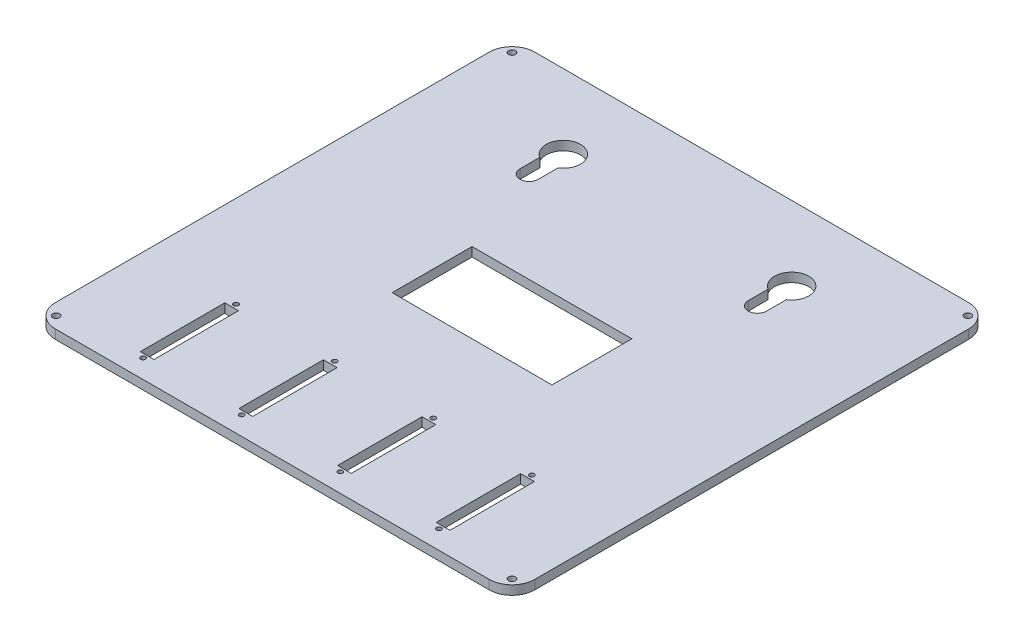
from build123d import *

# Parameters (mm, degrees)
SKETCH1_W              = 210
SKETCH1_H              = 210
MAINEXTRUDE_DEPTH      = 2
SKETCH1_6_R            = 1.5
SCREWHOLES_DEPTH       = 2
ROUNDEDCORNERS_R       = 10
SKETCH2_R              = 1.05
SKETCH2_W              = 6
SKETCH2_H              = 37
SKETCH2_W_2            = 70
SKETCH2_H_2            = 35
KNOTCHES_SLIDERS_DEPTH = 4
SKETCH6_R              = 2
SKETCH6_R_2            = 0.98
PCBHOLES_DEPTH         = 4
PCBROUNDS_R            = 2


with BuildPart() as part:
    # Sketch1 → MainExtrude (new body, symmetric)
    with BuildSketch(Plane(origin=(0, 0, 0), x_dir=(1, 0, 0), z_dir=(0, 1, 0))):
        Rectangle(SKETCH1_W, SKETCH1_H)
    extrude(amount=MAINEXTRUDE_DEPTH, both=True)

    # Sketch1_6 → ScrewHoles (cut, symmetric)
    with BuildSketch(Plane(origin=(0, 0, 0), x_dir=(1, 0, 0), z_dir=(0, 1, 0))):
        with Locations((-99.833273811, 99.833273811)):
            Circle(SKETCH1_6_R)
        with Locations((-99.833273811, -99.833273811)):
            Circle(SKETCH1_6_R)
        with Locations((99.833273811, -99.833273811)):
            Circle(SKETCH1_6_R)
        with Locations((99.833273811, 99.833273811)):
            Circle(SKETCH1_6_R)
    extrude(amount=SCREWHOLES_DEPTH, both=True, mode=Mode.SUBTRACT)

    # RoundedCorners
    roundedcorners_edges = [part.edges().sort_by_distance(p)[0] for p in [
        (-105, 0, -105),
        (-105, 0, 105),
        (105, 0, 105),
        (105, 0, -105),
    ]]
    fillet(roundedcorners_edges, radius=ROUNDEDCORNERS_R)

    # Sketch2 → Knotches_Sliders (cut)
    with BuildSketch(Plane(origin=(0, 2, 0), x_dir=(1, 0, 0), z_dir=(0, 1, 0))):
        with Locations((-64.8, -96.8)):
            Circle(SKETCH2_R)
        with Locations((-64.8, -56.1)):
            Circle(SKETCH2_R)
        with Locations((-21.6, -56.1)):
            Circle(SKETCH2_R)
        with Locations((-21.6, -96.8)):
            Circle(SKETCH2_R)
        with Locations((21.6, -56.1)):
            Circle(SKETCH2_R)
        with Locations((21.6, -96.8)):
            Circle(SKETCH2_R)
        with Locations((64.8, -56.1)):
            Circle(SKETCH2_R)
        with Locations((64.8, -96.8)):
            Circle(SKETCH2_R)
        with Locations((-64.8, -76.5)):
            Rectangle(SKETCH2_W, SKETCH2_H)
        with Locations((-21.6, -76.5)):
            Rectangle(SKETCH2_W, SKETCH2_H)
        with Locations((21.6, -76.5)):
            Rectangle(SKETCH2_W, SKETCH2_H)
        with Locations((64.8, -76.5)):
            Rectangle(SKETCH2_W, SKETCH2_H)
        with BuildLine():
            Line((-54, 57.5), (-54, 66.15571123))
            ThreePointArc((-54, 66.15571123), (-50, 80), (-46, 66.15571123))
            Line((-46, 66.15571123), (-46, 57.5))
            ThreePointArc((-46, 57.5), (-50, 53.5), (-54, 57.5))
        make_face()
        with BuildLine():
            Line((46, 57.5), (46, 66.15571123))
            ThreePointArc((46, 66.15571123), (50, 80), (54, 66.15571123))
            Line((54, 66.15571123), (54, 57.5))
            ThreePointArc((54, 57.5), (50, 53.5), (46, 57.5))
        make_face()
        Rectangle(SKETCH2_W_2, SKETCH2_H_2)
    extrude(amount=-KNOTCHES_SLIDERS_DEPTH, mode=Mode.SUBTRACT)

    # Sketch6 → PCBHoles (add)
    with BuildSketch(Plane(origin=(71.684316031, -2, 14.480918484), x_dir=(1, 0, 0), z_dir=(0, -1, 0))):
        with Locations((-22.524316031, 23.519081516)):
            Circle(SKETCH6_R)
        with Locations((-22.524316031, 23.519081516)):
            Circle(SKETCH6_R_2, mode=Mode.SUBTRACT)
        with Locations((13.315683969, 23.519081516)):
            Circle(SKETCH6_R)
        with Locations((13.315683969, 23.519081516)):
            Circle(SKETCH6_R_2, mode=Mode.SUBTRACT)
        with Locations((-22.524316031, -50.750918484)):
            Circle(SKETCH6_R)
        with Locations((-22.524316031, -50.750918484)):
            Circle(SKETCH6_R_2, mode=Mode.SUBTRACT)
        with Locations((13.315683969, -50.750918484)):
            Circle(SKETCH6_R)
        with Locations((13.315683969, -50.750918484)):
            Circle(SKETCH6_R_2, mode=Mode.SUBTRACT)
    extrude(amount=PCBHOLES_DEPTH)

    # PCBRounds
    pcbrounds_edges = [part.edges().sort_by_distance(p)[0] for p in [
        (47.16, -2, 38),
        (83, -2, 38),
        (47.16, -2, -36.27),
        (83, -2, -36.27),
    ]]
    fillet(pcbrounds_edges, radius=PCBROUNDS_R)


solid = part.part
